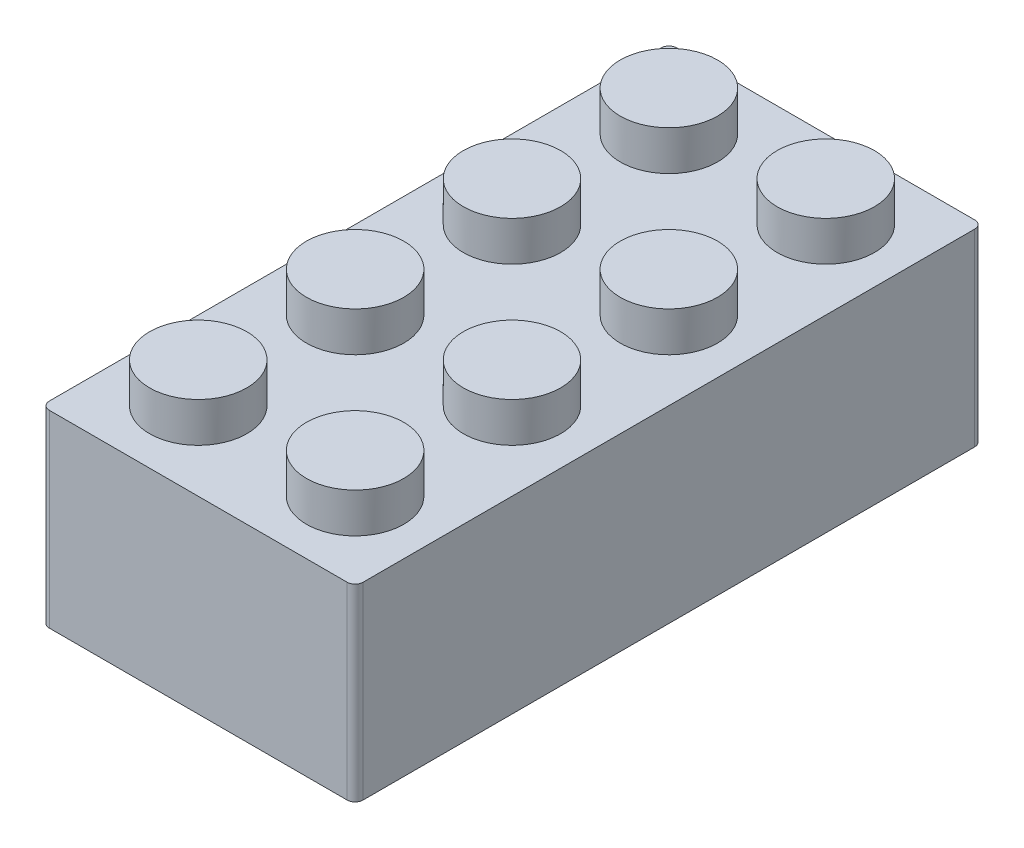
from build123d import *

# Parameters (mm, degrees)
SKETCH1_W           = 15.8
SKETCH1_H           = 31.6
BOSS_EXTRUDE1_DEPTH = 4.75
SKETCH2_R           = 2.45
BOSS_EXTRUDE2_DEPTH = 2
SKETCH3_W           = 12.8
SKETCH3_H           = 28.6
CUT_EXTRUDE1_DEPTH  = 4
SKETCH4_R           = 3.25
SKETCH4_R_2         = 2.45
BOSS_EXTRUDE3_DEPTH = 4
FILLET1_R           = 0.4


with BuildPart() as part:
    # Sketch1 → Boss-Extrude1 (new body, symmetric)
    with BuildSketch(Plane(origin=(0, 0, 0), x_dir=(1, 0, 0), z_dir=(0, 1, 0))):
        with Locations((7.9, 15.8)):
            Rectangle(SKETCH1_W, SKETCH1_H)
    extrude(amount=BOSS_EXTRUDE1_DEPTH, both=True)

    # Sketch2 → Boss-Extrude2 (add)
    with BuildSketch(Plane(origin=(0, 4.75, 0), x_dir=(1, 0, 0), z_dir=(0, 1, 0))):
        with Locations((3.95, 3.95)):
            Circle(SKETCH2_R)
        with Locations((11.85, 3.95)):
            Circle(SKETCH2_R)
        with Locations((11.85, 11.85)):
            Circle(SKETCH2_R)
        with Locations((3.95, 11.85)):
            Circle(SKETCH2_R)
        with Locations((3.95, 19.75)):
            Circle(SKETCH2_R)
        with Locations((11.85, 19.75)):
            Circle(SKETCH2_R)
        with Locations((3.95, 27.65)):
            Circle(SKETCH2_R)
        with Locations((11.85, 27.65)):
            Circle(SKETCH2_R)
    extrude(amount=BOSS_EXTRUDE2_DEPTH)

    # Sketch3 → Cut-Extrude1 (cut)
    with BuildSketch(Plane.XZ.offset(4.75)):
        with Locations((7.9, -15.8)):
            Rectangle(SKETCH3_W, SKETCH3_H)
    extrude(amount=-CUT_EXTRUDE1_DEPTH, mode=Mode.SUBTRACT)

    # Sketch4 → Boss-Extrude3 (add)
    with BuildSketch(Plane.XZ.offset(0.75)):
        with Locations((7.9, -7.9)):
            Circle(SKETCH4_R)
        with Locations((7.9, -7.9)):
            Circle(SKETCH4_R_2, mode=Mode.SUBTRACT)
        with Locations((7.9, -15.8)):
            Circle(SKETCH4_R)
        with Locations((7.9, -15.8)):
            Circle(SKETCH4_R_2, mode=Mode.SUBTRACT)
        with Locations((7.9, -23.7)):
            Circle(SKETCH4_R)
        with Locations((7.9, -23.7)):
            Circle(SKETCH4_R_2, mode=Mode.SUBTRACT)
    extrude(amount=BOSS_EXTRUDE3_DEPTH)

    # Fillet1
    fillet1_edges = [part.edges().sort_by_distance(p)[0] for p in [
        (0, 0, -31.6),
        (15.8, 0, -31.6),
        (15.8, 0, 0),
        (0, 0, 0),
    ]]
    fillet(fillet1_edges, radius=FILLET1_R)


solid = part.part
